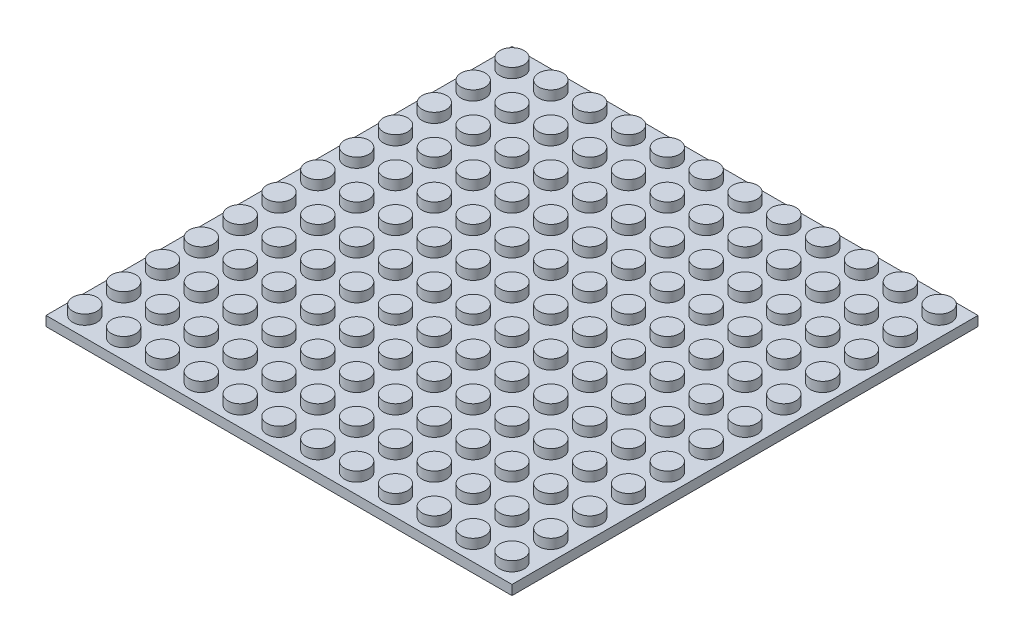
from build123d import *

# Parameters (mm, degrees)
SKETCH1_W           = 96
SKETCH1_H           = 96
BOSS_EXTRUDE1_DEPTH = 2
SKETCH2_R           = 2.5
BOSS_EXTRUDE2_DEPTH = 2


with BuildPart() as part:
    # Sketch1 → Boss-Extrude1 (new body)
    with BuildSketch(Plane(origin=(0, 0, 0), x_dir=(1, 0, 0), z_dir=(0, 1, 0))):
        with Locations((48, 48)):
            Rectangle(SKETCH1_W, SKETCH1_H)
    extrude(amount=BOSS_EXTRUDE1_DEPTH)

    # Sketch2 → Boss-Extrude2 (add)
    with BuildSketch(Plane(origin=(0, 2, 0), x_dir=(1, 0, 0), z_dir=(0, 1, 0))):
        with Locations((4, 4)):
            Circle(SKETCH2_R)
        with Locations((12, 4)):
            Circle(SKETCH2_R)
        with Locations((20, 4)):
            Circle(SKETCH2_R)
        with Locations((28, 4)):
            Circle(SKETCH2_R)
        with Locations((36, 4)):
            Circle(SKETCH2_R)
        with Locations((44, 4)):
            Circle(SKETCH2_R)
        with Locations((52, 4)):
            Circle(SKETCH2_R)
        with Locations((60, 4)):
            Circle(SKETCH2_R)
        with Locations((68, 4)):
            Circle(SKETCH2_R)
        with Locations((76, 4)):
            Circle(SKETCH2_R)
        with Locations((84, 4)):
            Circle(SKETCH2_R)
        with Locations((92, 4)):
            Circle(SKETCH2_R)
        with Locations((12, 12)):
            Circle(SKETCH2_R)
        with Locations((20, 12)):
            Circle(SKETCH2_R)
        with Locations((28, 12)):
            Circle(SKETCH2_R)
        with Locations((36, 12)):
            Circle(SKETCH2_R)
        with Locations((44, 12)):
            Circle(SKETCH2_R)
        with Locations((52, 12)):
            Circle(SKETCH2_R)
        with Locations((60, 12)):
            Circle(SKETCH2_R)
        with Locations((68, 12)):
            Circle(SKETCH2_R)
        with Locations((76, 12)):
            Circle(SKETCH2_R)
        with Locations((84, 12)):
            Circle(SKETCH2_R)
        with Locations((92, 12)):
            Circle(SKETCH2_R)
        with Locations((12, 20)):
            Circle(SKETCH2_R)
        with Locations((20, 20)):
            Circle(SKETCH2_R)
        with Locations((28, 20)):
            Circle(SKETCH2_R)
        with Locations((36, 20)):
            Circle(SKETCH2_R)
        with Locations((44, 20)):
            Circle(SKETCH2_R)
        with Locations((52, 20)):
            Circle(SKETCH2_R)
        with Locations((60, 20)):
            Circle(SKETCH2_R)
        with Locations((68, 20)):
            Circle(SKETCH2_R)
        with Locations((76, 20)):
            Circle(SKETCH2_R)
        with Locations((84, 20)):
            Circle(SKETCH2_R)
        with Locations((92, 20)):
            Circle(SKETCH2_R)
        with Locations((12, 28)):
            Circle(SKETCH2_R)
        with Locations((20, 28)):
            Circle(SKETCH2_R)
        with Locations((28, 28)):
            Circle(SKETCH2_R)
        with Locations((36, 28)):
            Circle(SKETCH2_R)
        with Locations((44, 28)):
            Circle(SKETCH2_R)
        with Locations((52, 28)):
            Circle(SKETCH2_R)
        with Locations((60, 28)):
            Circle(SKETCH2_R)
        with Locations((68, 28)):
            Circle(SKETCH2_R)
        with Locations((76, 28)):
            Circle(SKETCH2_R)
        with Locations((84, 28)):
            Circle(SKETCH2_R)
        with Locations((92, 28)):
            Circle(SKETCH2_R)
        with Locations((12, 36)):
            Circle(SKETCH2_R)
        with Locations((20, 36)):
            Circle(SKETCH2_R)
        with Locations((28, 36)):
            Circle(SKETCH2_R)
        with Locations((36, 36)):
            Circle(SKETCH2_R)
        with Locations((44, 36)):
            Circle(SKETCH2_R)
        with Locations((52, 36)):
            Circle(SKETCH2_R)
        with Locations((60, 36)):
            Circle(SKETCH2_R)
        with Locations((68, 36)):
            Circle(SKETCH2_R)
        with Locations((76, 36)):
            Circle(SKETCH2_R)
        with Locations((84, 36)):
            Circle(SKETCH2_R)
        with Locations((92, 36)):
            Circle(SKETCH2_R)
        with Locations((12, 44)):
            Circle(SKETCH2_R)
        with Locations((20, 44)):
            Circle(SKETCH2_R)
        with Locations((28, 44)):
            Circle(SKETCH2_R)
        with Locations((36, 44)):
            Circle(SKETCH2_R)
        with Locations((44, 44)):
            Circle(SKETCH2_R)
        with Locations((52, 44)):
            Circle(SKETCH2_R)
        with Locations((60, 44)):
            Circle(SKETCH2_R)
        with Locations((68, 44)):
            Circle(SKETCH2_R)
        with Locations((76, 44)):
            Circle(SKETCH2_R)
        with Locations((84, 44)):
            Circle(SKETCH2_R)
        with Locations((92, 44)):
            Circle(SKETCH2_R)
        with Locations((12, 52)):
            Circle(SKETCH2_R)
        with Locations((20, 52)):
            Circle(SKETCH2_R)
        with Locations((28, 52)):
            Circle(SKETCH2_R)
        with Locations((36, 52)):
            Circle(SKETCH2_R)
        with Locations((44, 52)):
            Circle(SKETCH2_R)
        with Locations((52, 52)):
            Circle(SKETCH2_R)
        with Locations((60, 52)):
            Circle(SKETCH2_R)
        with Locations((68, 52)):
            Circle(SKETCH2_R)
        with Locations((76, 52)):
            Circle(SKETCH2_R)
        with Locations((84, 52)):
            Circle(SKETCH2_R)
        with Locations((92, 52)):
            Circle(SKETCH2_R)
        with Locations((12, 60)):
            Circle(SKETCH2_R)
        with Locations((20, 60)):
            Circle(SKETCH2_R)
        with Locations((28, 60)):
            Circle(SKETCH2_R)
        with Locations((36, 60)):
            Circle(SKETCH2_R)
        with Locations((44, 60)):
            Circle(SKETCH2_R)
        with Locations((52, 60)):
            Circle(SKETCH2_R)
        with Locations((60, 60)):
            Circle(SKETCH2_R)
        with Locations((68, 60)):
            Circle(SKETCH2_R)
        with Locations((76, 60)):
            Circle(SKETCH2_R)
        with Locations((84, 60)):
            Circle(SKETCH2_R)
        with Locations((92, 60)):
            Circle(SKETCH2_R)
        with Locations((12, 68)):
            Circle(SKETCH2_R)
        with Locations((20, 68)):
            Circle(SKETCH2_R)
        with Locations((28, 68)):
            Circle(SKETCH2_R)
        with Locations((36, 68)):
            Circle(SKETCH2_R)
        with Locations((44, 68)):
            Circle(SKETCH2_R)
        with Locations((52, 68)):
            Circle(SKETCH2_R)
        with Locations((60, 68)):
            Circle(SKETCH2_R)
        with Locations((68, 68)):
            Circle(SKETCH2_R)
        with Locations((76, 68)):
            Circle(SKETCH2_R)
        with Locations((84, 68)):
            Circle(SKETCH2_R)
        with Locations((92, 68)):
            Circle(SKETCH2_R)
        with Locations((12, 76)):
            Circle(SKETCH2_R)
        with Locations((20, 76)):
            Circle(SKETCH2_R)
        with Locations((28, 76)):
            Circle(SKETCH2_R)
        with Locations((36, 76)):
            Circle(SKETCH2_R)
        with Locations((44, 76)):
            Circle(SKETCH2_R)
        with Locations((52, 76)):
            Circle(SKETCH2_R)
        with Locations((60, 76)):
            Circle(SKETCH2_R)
        with Locations((68, 76)):
            Circle(SKETCH2_R)
        with Locations((76, 76)):
            Circle(SKETCH2_R)
        with Locations((84, 76)):
            Circle(SKETCH2_R)
        with Locations((92, 76)):
            Circle(SKETCH2_R)
        with Locations((12, 84)):
            Circle(SKETCH2_R)
        with Locations((20, 84)):
            Circle(SKETCH2_R)
        with Locations((28, 84)):
            Circle(SKETCH2_R)
        with Locations((36, 84)):
            Circle(SKETCH2_R)
        with Locations((44, 84)):
            Circle(SKETCH2_R)
        with Locations((52, 84)):
            Circle(SKETCH2_R)
        with Locations((60, 84)):
            Circle(SKETCH2_R)
        with Locations((68, 84)):
            Circle(SKETCH2_R)
        with Locations((76, 84)):
            Circle(SKETCH2_R)
        with Locations((84, 84)):
            Circle(SKETCH2_R)
        with Locations((92, 84)):
            Circle(SKETCH2_R)
        with Locations((12, 92)):
            Circle(SKETCH2_R)
        with Locations((20, 92)):
            Circle(SKETCH2_R)
        with Locations((28, 92)):
            Circle(SKETCH2_R)
        with Locations((36, 92)):
            Circle(SKETCH2_R)
        with Locations((44, 92)):
            Circle(SKETCH2_R)
        with Locations((52, 92)):
            Circle(SKETCH2_R)
        with Locations((60, 92)):
            Circle(SKETCH2_R)
        with Locations((68, 92)):
            Circle(SKETCH2_R)
        with Locations((76, 92)):
            Circle(SKETCH2_R)
        with Locations((84, 92)):
            Circle(SKETCH2_R)
        with Locations((92, 92)):
            Circle(SKETCH2_R)
        with Locations((4, 12)):
            Circle(SKETCH2_R)
        with Locations((4, 20)):
            Circle(SKETCH2_R)
        with Locations((4, 28)):
            Circle(SKETCH2_R)
        with Locations((4, 36)):
            Circle(SKETCH2_R)
        with Locations((4, 44)):
            Circle(SKETCH2_R)
        with Locations((4, 52)):
            Circle(SKETCH2_R)
        with Locations((4, 60)):
            Circle(SKETCH2_R)
        with Locations((4, 68)):
            Circle(SKETCH2_R)
        with Locations((4, 76)):
            Circle(SKETCH2_R)
        with Locations((4, 84)):
            Circle(SKETCH2_R)
        with Locations((4, 92)):
            Circle(SKETCH2_R)
    extrude(amount=BOSS_EXTRUDE2_DEPTH)


solid = part.part
